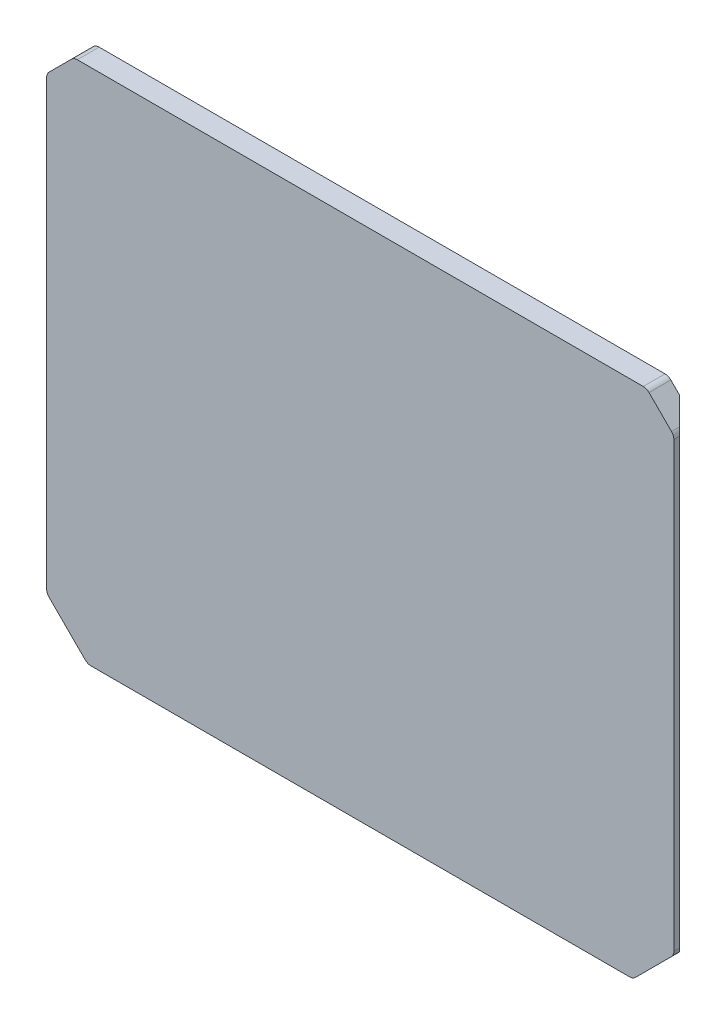
from build123d import *

# Parameters (mm, degrees)
BASE_EXTRUDE_DEPTH    = 8
SK_RPNING1_SIDER_SIZE = 6
R3_RUNDINGER_R        = 3


with BuildPart() as part:
    # Sketch1 → Base-Extrude (new body)
    with BuildSketch(Plane.XY):
        Polygon((100, 0), (115, 15), (115, 180), (105, 190), (-105, 190), (-115, 180), (-115, 15), (-100, 0), align=None)
    extrude(amount=BASE_EXTRUDE_DEPTH)

    # Skærpning1 sider
    sk_rpning1_sider_edges = [part.edges().sort_by_distance(p)[0] for p in [
        (-115, 97.5, 0),
        (115, 97.5, 0),
    ]]
    chamfer(sk_rpning1_sider_edges, length=SK_RPNING1_SIDER_SIZE)

    # R3 rundinger
    r3_rundinger_edges = [part.edges().sort_by_distance(p)[0] for p in [
        (-100, 0, 4),
        (-115, 15, 7),
        (-115, 180, 7),
        (-105, 190, 4),
        (105, 190, 4),
        (115, 180, 7),
        (115, 15, 7),
        (100, 0, 4),
    ]]
    fillet(r3_rundinger_edges, radius=R3_RUNDINGER_R)


solid = part.part
